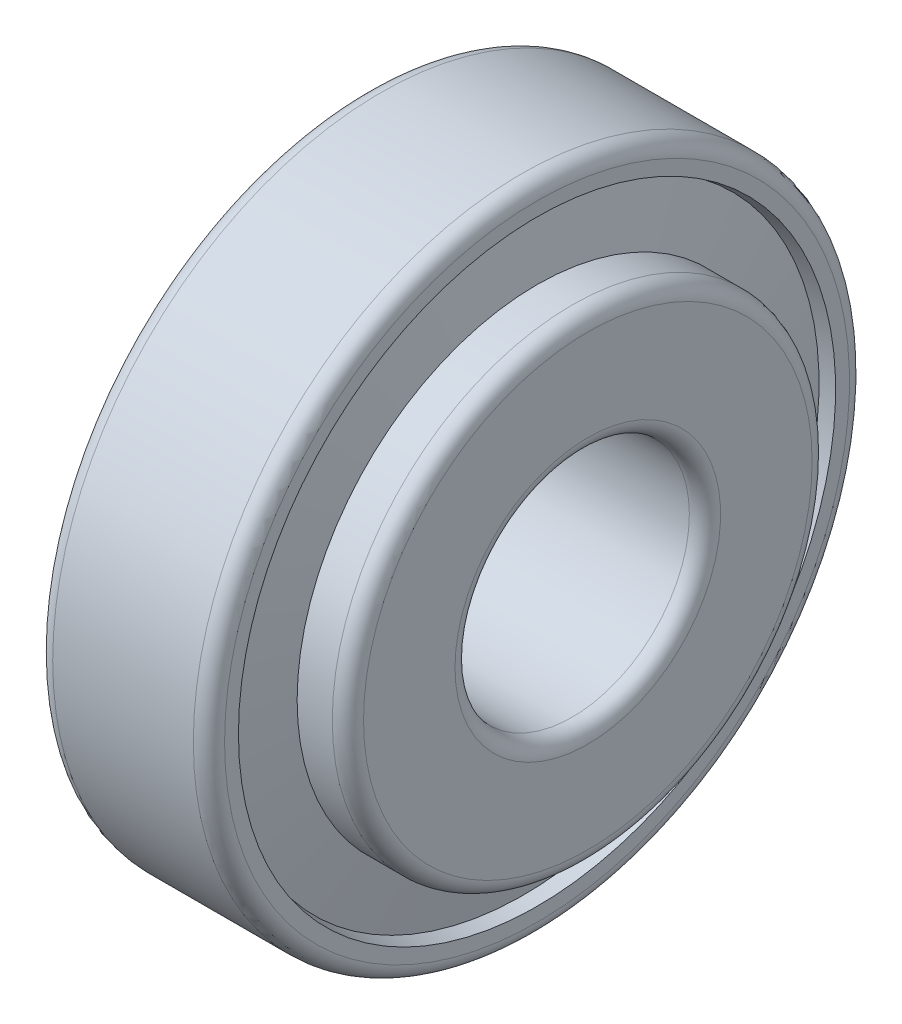
from build123d import *


with BuildPart() as part:
    # Эскиз1 → Повернуть1 (revolve)
    with BuildSketch(Plane.XY):
        with BuildLine():
            Line((2.012218894, 17.08887297), (0, 16.636))
            Line((0, 16.636), (0, 20))
            ThreePointArc((0, 20), (0.292893219, 20.707106781), (1, 21))
            Line((1, 21), (10, 21))
            ThreePointArc((10, 21), (10.707106781, 20.707106781), (11, 20))
            Line((11, 20), (11, 19.111676323))
            Line((11, 19.111676323), (10.133354167, 18.916627726))
            Line((10.133354167, 18.916627726), (11, 14.355372274))
            Line((11, 14.355372274), (11, 15.355372274))
            Line((11, 15.355372274), (13.25, 15.355372274))
            ThreePointArc((13.25, 15.355372274), (13.957106781, 15.062479055), (14.25, 14.355372274))
            Line((14.25, 14.355372274), (14.25, 8.5))
            ThreePointArc((14.25, 8.5), (13.957106781, 7.792893219), (13.25, 7.5))
            Line((13.25, 7.5), (2.25, 7.5))
            ThreePointArc((2.25, 7.5), (1.542893219, 7.792893219), (1.25, 8.5))
            Line((1.25, 8.5), (1.25, 13.077228357))
            Line((1.25, 13.077228357), (2.774437789, 13.077228357))
            Line((2.774437789, 13.077228357), (2.012218894, 17.08887297))
        make_face()
    revolve(axis=Axis((-882.527700014, 0, 0), (1, 0, 0)))


solid = part.part
